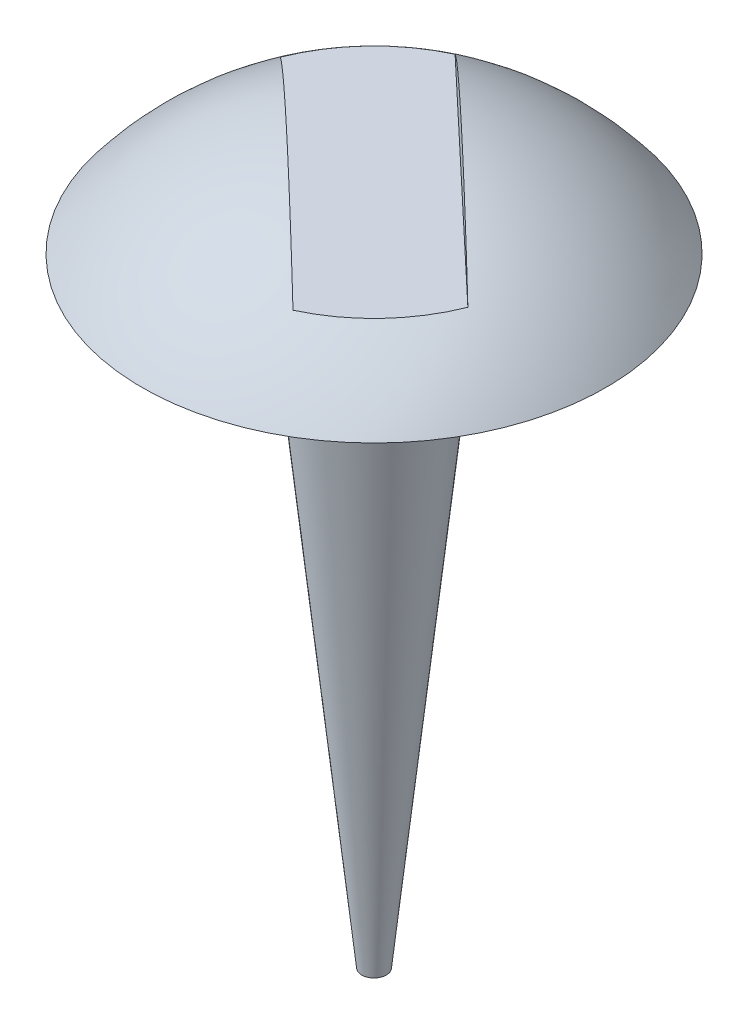
from build123d import *

# Parameters (mm, degrees)
SKETCH_3_R          = 0.1
EXTRUDE_1_DEPTH     = 0.8
EXTRUDE_1_TAPER     = 6
CUT_EXTRUDE_1_DEPTH = 5


with BuildPart() as part:
    # 草图2 one side → 旋转1 (revolve)
    with BuildSketch(Plane.XY):
        with BuildLine():
            Line((0, 0), (0, 0.147503795))
            ThreePointArc((0, 0.147503795), (-0.167150658, 0.108633694), (-0.3, 0))
            Line((-0.3, 0), (0, 0))
        make_face()
    revolve(axis=Axis((0, -0.078044802, 0), (0, 1, 0)))

    # 草图3 → 凸台-拉伸1 (add)
    with BuildSketch(Plane.XZ):
        Circle(SKETCH_3_R)
    extrude(amount=EXTRUDE_1_DEPTH, taper=EXTRUDE_1_TAPER)

    # 草图8 → 切除-拉伸1 (cut)
    with BuildSketch(Plane.XZ.offset(-0.08)):
        Polygon((-0.248199097, -0.234130992), (0, 0), (0.251445487, 0.237193374), (0.196550222, 0.295387102), (-0.054895265, 0.058193727), (-0.303094362, -0.175937265), align=None)
        Polygon((0.251445487, 0.237193374), (0, 0), (-0.248199097, -0.234130992), (-0.193303832, -0.29232472), (0.054895265, -0.058193727), (0.306340752, 0.178999647), align=None)
    extrude(amount=-CUT_EXTRUDE_1_DEPTH, mode=Mode.SUBTRACT)


solid = part.part
